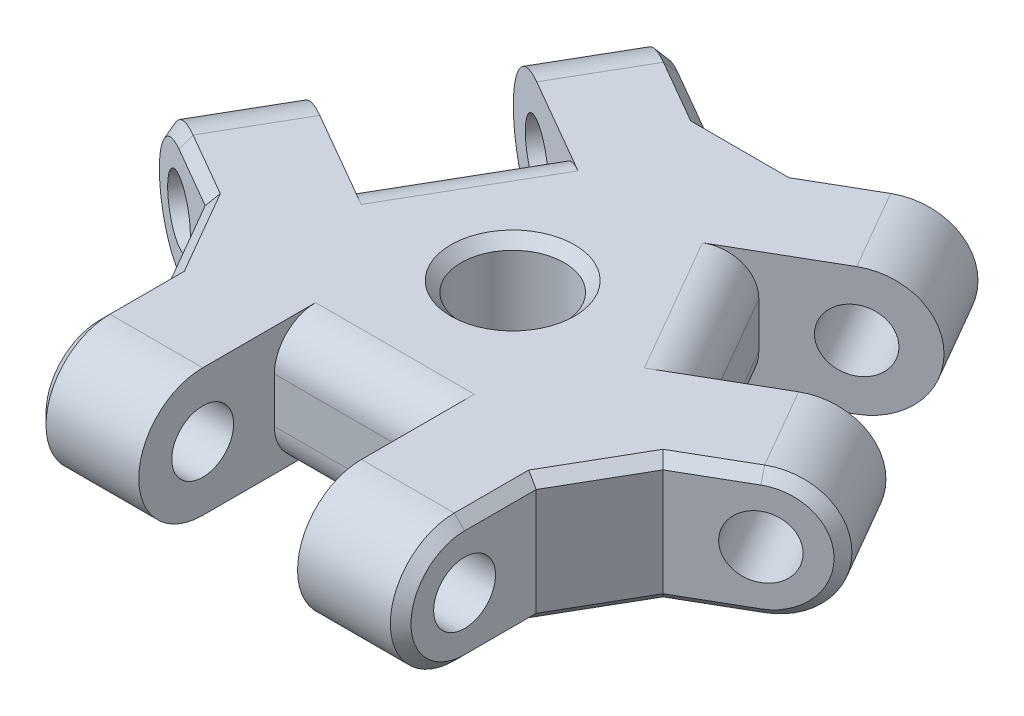
from build123d import *

# Parameters (mm, degrees)
SKETCH1_R           = 2.5
BOSS_EXTRUDE1_DEPTH = 3.1
CUT_EXTRUDE1_START  = -26.968876556
SKETCH2_R           = 1.5
CUT_EXTRUDE1_DEPTH  = 36.237753113
CIRPATTERN5_COUNT   = 3
FILLET2_R           = 2
CHAMFER1_SIZE       = 0.5


with BuildPart() as part:
    # Sketch1 → Boss-Extrude1 (new body, symmetric)
    with BuildSketch(Plane(origin=(0, 0, 0), x_dir=(1, 0, 0), z_dir=(0, 1, 0))):
        Polygon((-8.85, -7.707626094), (-8.85, -14.657626094), (-3.85, -14.657626094), (-3.85, -7.707626094), (3.85, -7.707626094), (3.85, -14.657626094), (8.85, -14.657626094), (8.85, -7.707626094), (11.1, -3.810511777), (17.118876556, -0.335511777), (14.618876556, 3.994615242), (8.6, 0.519615242), (4.75, 7.188010851), (10.768876556, 10.663010851), (8.268876556, 14.99313787), (2.25, 11.51813787), (-2.25, 11.51813787), (-8.268876556, 14.99313787), (-10.768876556, 10.663010851), (-4.75, 7.188010851), (-8.6, 0.519615242), (-14.618876556, 3.994615242), (-17.118876556, -0.335511777), (-11.1, -3.810511777), align=None)
        Circle(SKETCH1_R, mode=Mode.SUBTRACT)
    extrude(amount=BOSS_EXTRUDE1_DEPTH, both=True)

    # Sketch2 → Cut-Extrude1 (cut)
    with BuildSketch(Plane.ZY.offset(8.85).offset(CUT_EXTRUDE1_START)):
        with Locations((11.182626094, 0)):
            Circle(SKETCH2_R)
        with BuildLine():
            Line((11.182626094, 3.1), (14.657626094, 3.1))
            Line((14.657626094, 3.1), (14.657626094, -3.1))
            Line((14.657626094, -3.1), (11.182626094, -3.1))
            ThreePointArc((11.182626094, -3.1), (14.282626094, 0), (11.182626094, 3.1))
        make_face()
    cut_extrude1 = extrude(amount=CUT_EXTRUDE1_DEPTH, mode=Mode.SUBTRACT)

    # CirPattern5: Cut-Extrude1 ×3 about axis
    cirpattern5_axis = Axis((0, 3.1, 0), (0, -1, 0))
    for i in range(1, CIRPATTERN5_COUNT):
        add(cut_extrude1.rotate(cirpattern5_axis, i * 360 / CIRPATTERN5_COUNT), mode=Mode.SUBTRACT)

    # Fillet2
    fillet2_edges = [part.edges().sort_by_distance(p)[0] for p in [
        (6.675, 3.1, -3.853813047),
        (0, -3.1, 7.707626094),
        (-6.675, -3.1, -3.853813047),
        (6.675, -3.1, -3.853813047),
        (-6.675, 3.1, -3.853813047),
        (0, 3.1, 7.707626094),
    ]]
    fillet(fillet2_edges, radius=FILLET2_R)

    # Chamfer1
    chamfer1_edges = [part.edges().sort_by_distance(p)[0] for p in [
        (-12.604719139, -3.1, 2.941761777),
        (-12.604719139, 3.1, 2.941761777),
        (-16.79411703, 0, 0.523011777),
        (3.754719139, -3.1, -12.38688787),
        (3.754719139, 3.1, -12.38688787),
        (7.94411703, 0, -14.80563787),
        (16.79411703, 0, 0.523011777),
        (-7.94411703, 0, -14.80563787),
        (-8.85, -3.1, 9.445126094),
        (-9.975, -3.1, 5.759068935),
        (-3.754719139, -3.1, -12.38688787),
        (0, -3.1, -11.51813787),
        (12.604719139, -3.1, 2.941761777),
        (9.975, -3.1, 5.759068935),
        (0, 3.1, -11.51813787),
        (-3.754719139, 3.1, -12.38688787),
        (9.975, 3.1, 5.759068935),
        (-2.5, -3.1, 0),
        (-2.5, 3.1, 0),
        (-9.975, 3.1, 5.759068935),
        (8.85, -3.1, 9.445126094),
        (-8.85, 3.1, 9.445126094),
        (8.85, 3.1, 9.445126094),
        (8.85, 0, 14.282626094),
        (-8.85, 0, 14.282626094),
        (12.604719139, 3.1, 2.941761777),
    ]]
    chamfer(chamfer1_edges, length=CHAMFER1_SIZE)


solid = part.part
